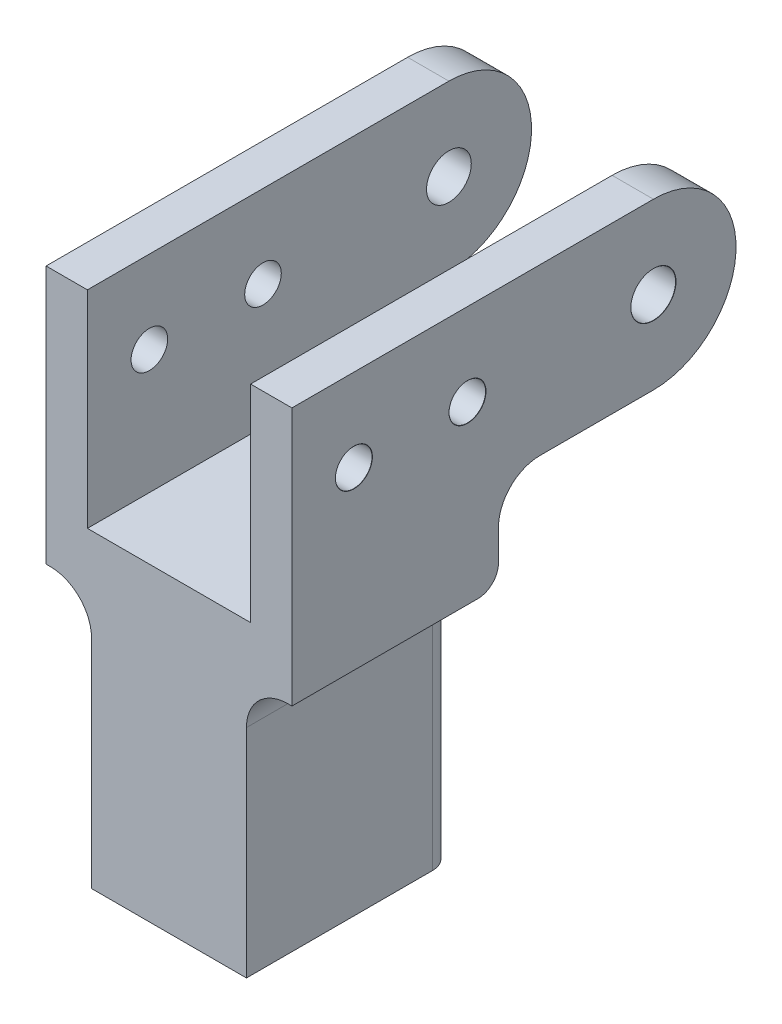
from build123d import *

# Parameters (mm, degrees)
BOSS_EXTRUDE1_DEPTH            = 25.4
SKETCH2_W                      = 12.7
SKETCH2_H                      = 12.7
SKETCH2_H_2                    = 5.08
CUT_EXTRUDE1_DEPTH             = 31.75
M4_CLEARANCE_HOLE4_D           = 4.5
M4_CLEARANCE_HOLE4_DEPTH       = 10.16
M4_CLEARANCE_HOLE4_CSINK_D     = 4.55
M4_CLEARANCE_HOLE4_CSINK_ANGLE = 100
M4_CLEARANCE_HOLE4_TIP         = 1.351936393
SKETCH6_W                      = 5.08
SKETCH6_H                      = 20.32
BOSS_EXTRUDE2_DEPTH            = 19.05
BOSS_EXTRUDE3_DEPTH            = 5.08
BOSS_EXTRUDE4_DEPTH            = 5.08
M4_CLEARANCE_HOLE5_D           = 4.5
M4_CLEARANCE_HOLE5_DEPTH       = 30.226
M4_CLEARANCE_HOLE5_CSINK_D     = 4.55
M4_CLEARANCE_HOLE5_CSINK_ANGLE = 100
M4_CLEARANCE_HOLE5_TIP         = 1.351936393
M5_CLEARANCE_HOLE1_D           = 5.5
M5_CLEARANCE_HOLE1_DEPTH       = 30.226
M5_CLEARANCE_HOLE1_CSINK_D     = 5.55
M5_CLEARANCE_HOLE1_CSINK_ANGLE = 100
M5_CLEARANCE_HOLE1_TIP         = 1.652366702
FILLET1_R                      = 5.08
FILLET2_R                      = 2.54


with BuildPart() as part:
    # Sketch1 → Boss-Extrude1 (new body)
    with BuildSketch(Plane.XY):
        Polygon((-15.113, 0), (-10.033, 0), (-10.033, -25.4), (10.033, -25.4), (10.033, 0), (15.113, 0), (15.113, -31.75), (9.525, -31.75), (9.525, -63.5), (-9.525, -63.5), (-9.525, -31.75), (-15.113, -31.75), align=None)
    extrude(amount=BOSS_EXTRUDE1_DEPTH)

    # Sketch2 → Cut-Extrude1 (cut)
    with BuildSketch(Plane.XZ.offset(63.5)):
        with Locations((0, 16.51)):
            Rectangle(SKETCH2_W, SKETCH2_H)
        with Locations((0, 5.08)):
            Rectangle(SKETCH2_W, SKETCH2_H_2)
    extrude(amount=-CUT_EXTRUDE1_DEPTH, mode=Mode.SUBTRACT)

    # M4 Clearance Hole4
    with Locations(Plane(origin=(0, 0, 0), x_dir=(-1, 0, 0), z_dir=(0, 0, -1))):
        with Locations((0, -57.15), (0, -45.72)):
            CounterSinkHole(M4_CLEARANCE_HOLE4_D / 2, M4_CLEARANCE_HOLE4_CSINK_D / 2, depth=M4_CLEARANCE_HOLE4_DEPTH, counter_sink_angle=M4_CLEARANCE_HOLE4_CSINK_ANGLE)
            with Locations((0, 0, -(M4_CLEARANCE_HOLE4_DEPTH + M4_CLEARANCE_HOLE4_TIP / 2))):  # 118° drill point
                Cone(0, M4_CLEARANCE_HOLE4_D / 2, M4_CLEARANCE_HOLE4_TIP, mode=Mode.SUBTRACT)

    # Sketch6 → Boss-Extrude2 (add)
    with BuildSketch(Plane(origin=(0, 0, 0), x_dir=(-1, 0, 0), z_dir=(0, 0, -1))):
        with Locations((-12.573, -10.16)):
            Rectangle(SKETCH6_W, SKETCH6_H)
        with Locations((12.573, -10.16)):
            Rectangle(SKETCH6_W, SKETCH6_H)
    extrude(amount=BOSS_EXTRUDE2_DEPTH)

    # Sketch7 → Boss-Extrude3 (add)
    with BuildSketch(Plane(origin=(15.113, 0, 0), x_dir=(0, 0, -1), z_dir=(1, 0, 0))):
        with BuildLine():
            Line((19.05, -20.32), (19.05, 0))
            ThreePointArc((19.05, 0), (29.21, -10.16), (19.05, -20.32))
        make_face()
    extrude(amount=-BOSS_EXTRUDE3_DEPTH)

    # Sketch8 → Boss-Extrude4 (add)
    with BuildSketch(Plane.ZY.offset(15.113)):
        with BuildLine():
            Line((-19.05, -20.32), (-19.05, 0))
            ThreePointArc((-19.05, 0), (-29.21, -10.16), (-19.05, -20.32))
        make_face()
    extrude(amount=-BOSS_EXTRUDE4_DEPTH)

    # M4 Clearance Hole5
    with Locations(Plane(origin=(15.113, 0, 0), x_dir=(0, 0, -1), z_dir=(1, 0, 0))):
        with Locations((-17.78, -10.16), (-3.81, -10.16)):
            CounterSinkHole(M4_CLEARANCE_HOLE5_D / 2, M4_CLEARANCE_HOLE5_CSINK_D / 2, depth=M4_CLEARANCE_HOLE5_DEPTH, counter_sink_angle=M4_CLEARANCE_HOLE5_CSINK_ANGLE)
            with Locations((0, 0, -(M4_CLEARANCE_HOLE5_DEPTH + M4_CLEARANCE_HOLE5_TIP / 2))):  # 118° drill point
                Cone(0, M4_CLEARANCE_HOLE5_D / 2, M4_CLEARANCE_HOLE5_TIP, mode=Mode.SUBTRACT)

    # M5 Clearance Hole1
    with Locations(Plane(origin=(15.113, 0, 0), x_dir=(0, 0, -1), z_dir=(1, 0, 0))):
        with Locations((19.05, -10.16)):
            CounterSinkHole(M5_CLEARANCE_HOLE1_D / 2, M5_CLEARANCE_HOLE1_CSINK_D / 2, depth=M5_CLEARANCE_HOLE1_DEPTH, counter_sink_angle=M5_CLEARANCE_HOLE1_CSINK_ANGLE)
            with Locations((0, 0, -(M5_CLEARANCE_HOLE1_DEPTH + M5_CLEARANCE_HOLE1_TIP / 2))):  # 118° drill point
                Cone(0, M5_CLEARANCE_HOLE1_D / 2, M5_CLEARANCE_HOLE1_TIP, mode=Mode.SUBTRACT)

    # Fillet1
    fillet1_edges = [part.edges().sort_by_distance(p)[0] for p in [
        (12.573, -20.32, 0),
        (-12.573, -20.32, 0),
        (-9.525, -31.75, 12.7),
        (9.525, -31.75, 12.7),
    ]]
    fillet(fillet1_edges, radius=FILLET1_R)

    # Fillet2
    fillet2_edges = [part.edges().sort_by_distance(p)[0] for p in [
        (9.525, -50.165, 0),
        (14.859, -31.75, 0),
        (-9.525, -50.165, 0),
        (-14.859, -31.75, 0),
        (-11.012897552, -33.237897552, 0),
        (11.012897552, -33.237897552, 0),
    ]]
    fillet(fillet2_edges, radius=FILLET2_R)


solid = part.part
